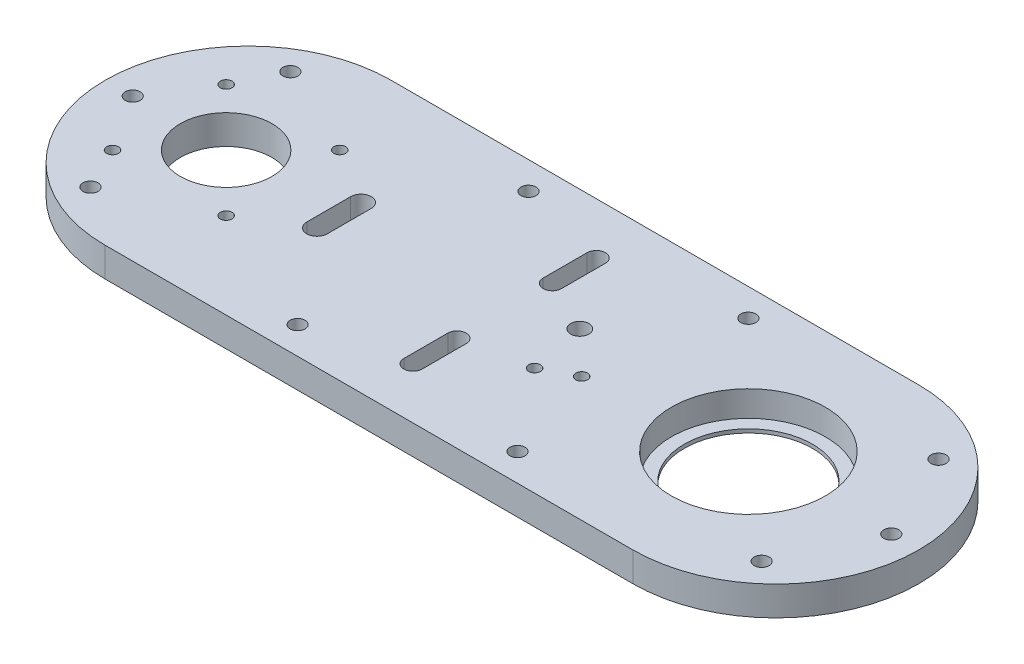
from build123d import *

# Parameters (mm, degrees)
BOSS_EXTRUDE1_DEPTH                                 = 8
SKETCH2_R                                           = 17.5
SKETCH2_R_2                                         = 12.5
CUT_EXTRUDE1_DEPTH                                  = 9
SKETCH3_R                                           = 1.6
CUT_EXTRUDE2_DEPTH                                  = 9
SKETCH4_R                                           = 2.05
CUT_EXTRUDE3_DEPTH                                  = 9
CUT_EXTRUDE4_DEPTH                                  = 9
SKETCH6_R                                           = 1.6
SKETCH6_R_2                                         = 2.5
CUT_EXTRUDE5_DEPTH                                  = 9
SKETCH7_R                                           = 21
CUT_EXTRUDE6_DEPTH                                  = 7
CSK_FOR_M4_COUNTERSUNK_FLAT_HEAD_SCREW1_D           = 4.1
CSK_FOR_M4_COUNTERSUNK_FLAT_HEAD_SCREW1_CSINK_D     = 9.1
CSK_FOR_M4_COUNTERSUNK_FLAT_HEAD_SCREW1_CSINK_ANGLE = 90
CUT_EXTRUDE7_DEPTH                                  = 9


with BuildPart() as part:
    # Sketch1 → Boss-Extrude1 (new body)
    with BuildSketch(Plane(origin=(0, 0, 0), x_dir=(1, 0, 0), z_dir=(0, 1, 0))):
        with BuildLine():
            Line((-144, 39), (0, 39))
            ThreePointArc((0, 39), (39, 0), (0, -39))
            Line((0, -39), (-144, -39))
            ThreePointArc((-144, -39), (-183, 0), (-144, 39))
        make_face()
    extrude(amount=BOSS_EXTRUDE1_DEPTH)

    # Sketch2 → Cut-Extrude1 (cut, through all)
    with BuildSketch(Plane(origin=(0, 8, 0), x_dir=(1, 0, 0), z_dir=(0, 1, 0))):
        with Locations((-7.5, 0)):
            Circle(SKETCH2_R)
        with Locations((-150, 0)):
            Circle(SKETCH2_R_2)
    extrude(amount=-CUT_EXTRUDE1_DEPTH, mode=Mode.SUBTRACT)

    # Sketch3 → Cut-Extrude2 (cut, through all)
    with BuildSketch(Plane(origin=(0, 8, 0), x_dir=(1, 0, 0), z_dir=(0, 1, 0))):
        with Locations((-165.5, 15.5)):
            Circle(SKETCH3_R)
        with Locations((-134.5, 15.5)):
            Circle(SKETCH3_R)
        with Locations((-134.5, -15.5)):
            Circle(SKETCH3_R)
        with Locations((-165.5, -15.5)):
            Circle(SKETCH3_R)
    extrude(amount=-CUT_EXTRUDE2_DEPTH, mode=Mode.SUBTRACT)

    # Sketch4 → Cut-Extrude3 (cut, through all)
    with BuildSketch(Plane(origin=(0, 8, 0), x_dir=(1, 0, 0), z_dir=(0, 1, 0))):
        with Locations((-159.75, 27.279800219)):
            Circle(SKETCH4_R)
        with Locations((-175.5, 0)):
            Circle(SKETCH4_R)
        with Locations((-159.75, -27.279800219)):
            Circle(SKETCH4_R)
        with Locations((20.247809705, 24.130399958)):
            Circle(SKETCH4_R)
        with Locations((31.5, 0)):
            Circle(SKETCH4_R)
        with Locations((20.247809705, -24.130399958)):
            Circle(SKETCH4_R)
        with Locations((-99, 31.5)):
            Circle(SKETCH4_R)
        with Locations((-39, 31.5)):
            Circle(SKETCH4_R)
        with Locations((-39, -31.5)):
            Circle(SKETCH4_R)
        with Locations((-99, -31.5)):
            Circle(SKETCH4_R)
    extrude(amount=-CUT_EXTRUDE3_DEPTH, mode=Mode.SUBTRACT)

    # Sketch5 → Cut-Extrude4 (cut, through all)
    with BuildSketch(Plane(origin=(0, 8, 0), x_dir=(1, 0, 0), z_dir=(0, 1, 0))):
        with BuildLine():
            Line((-76.5, -25), (-76.5, -13))
            ThreePointArc((-76.5, -13), (-74, -10.5), (-71.5, -13))
            Line((-71.5, -13), (-71.5, -25))
            ThreePointArc((-71.5, -25), (-74, -27.5), (-76.5, -25))
        make_face()
        with BuildLine():
            Line((-71.5, 25), (-71.5, 13))
            ThreePointArc((-71.5, 13), (-74, 10.5), (-76.5, 13))
            Line((-76.5, 13), (-76.5, 25))
            ThreePointArc((-76.5, 25), (-74, 27.5), (-71.5, 25))
        make_face()
    extrude(amount=-CUT_EXTRUDE4_DEPTH, mode=Mode.SUBTRACT)

    # Sketch6 → Cut-Extrude5 (cut, through all)
    with BuildSketch(Plane(origin=(0, 8, 0), x_dir=(1, 0, 0), z_dir=(0, 1, 0))):
        with Locations((-48, -5)):
            Circle(SKETCH6_R)
        with Locations((-56.388002132, -9.459979846)):
            Circle(SKETCH6_R)
        with Locations((-59.5, 6)):
            Circle(SKETCH6_R_2)
    extrude(amount=-CUT_EXTRUDE5_DEPTH, mode=Mode.SUBTRACT)

    # Sketch7 → Cut-Extrude6 (cut)
    with BuildSketch(Plane(origin=(0, 8, 0), x_dir=(1, 0, 0), z_dir=(0, 1, 0))):
        with Locations((-7.5, 0)):
            Circle(SKETCH7_R)
    extrude(amount=-CUT_EXTRUDE6_DEPTH, mode=Mode.SUBTRACT)

    # CSK for M4 Countersunk Flat Head Screw1 (through all)
    with Locations(Plane(origin=(-159.75, 0, 27.279800219), x_dir=(0, 0, -1), z_dir=(0, -1, 0))):
        with Locations((0, 0), (27.279800219, -15.75), (54.559600438, 0), (-4.220199781, 60.75), (58.779800219, 60.75), (-4.220199781, 120.75), (58.779800219, 120.75), (3.149400261, 179.997809705), (27.279800219, 191.25), (51.410200177, 179.997809705)):
            CounterSinkHole(CSK_FOR_M4_COUNTERSUNK_FLAT_HEAD_SCREW1_D / 2, CSK_FOR_M4_COUNTERSUNK_FLAT_HEAD_SCREW1_CSINK_D / 2, counter_sink_angle=CSK_FOR_M4_COUNTERSUNK_FLAT_HEAD_SCREW1_CSINK_ANGLE)

    # Sketch9 → Cut-Extrude7 (cut, through all)
    with BuildSketch(Plane(origin=(0, 8, 0), x_dir=(1, 0, 0), z_dir=(0, 1, 0))):
        with BuildLine():
            Line((-122, -6), (-122, 6))
            ThreePointArc((-122, 6), (-119.2, 8.8), (-116.4, 6))
            Line((-116.4, 6), (-116.4, -6))
            ThreePointArc((-116.4, -6), (-119.2, -8.8), (-122, -6))
        make_face()
    extrude(amount=-CUT_EXTRUDE7_DEPTH, mode=Mode.SUBTRACT)


solid = part.part
